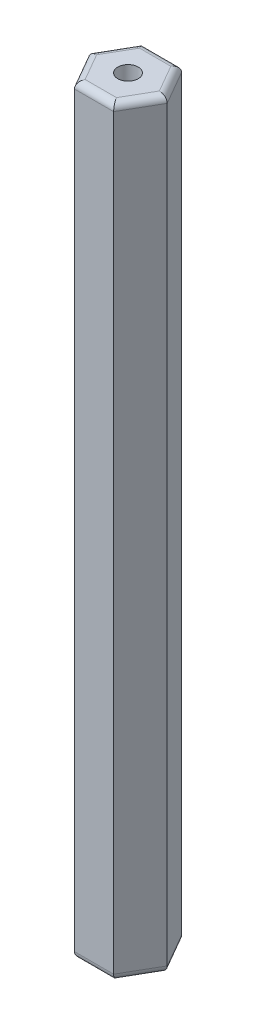
from build123d import *

# Parameters (mm, degrees)
RESSALTO_EXTRUS_O1_DEPTH = 56
FILETE1_R                = 0.5
ESBO_O2_R                = 0.751353762
CORTE_EXTRUS_O1_DEPTH    = 57


with BuildPart() as part:
    # Esboço1 → Ressalto-extrusão1 (new body)
    with BuildSketch(Plane.XZ.offset(30)):
        Polygon((-1.443375673, -2.5), (1.443375673, -2.5), (2.886751346, 0), (1.443375673, 2.5), (-1.443375673, 2.5), (-2.886751346, 0), align=None)
    extrude(amount=-RESSALTO_EXTRUS_O1_DEPTH)

    # Filete1
    filete1_edges = [part.edges().sort_by_distance(p)[0] for p in [
        (2.165063509, 26, -1.25),
        (2.165063509, 26, 1.25),
        (0, 26, 2.5),
        (-2.165063509, 26, 1.25),
        (-2.165063509, 26, -1.25),
        (-2.165063509, -30, 1.25),
        (0, -30, 2.5),
        (2.165063509, -30, 1.25),
        (2.165063509, -30, -1.25),
        (0, -30, -2.5),
        (-2.165063509, -30, -1.25),
        (0, 26, -2.5),
    ]]
    fillet(filete1_edges, radius=FILETE1_R)

    # Esboço2 → Corte-extrusão1 (cut, through all)
    with BuildSketch(Plane.XZ.offset(30)):
        Circle(ESBO_O2_R)
    extrude(amount=-CORTE_EXTRUS_O1_DEPTH, mode=Mode.SUBTRACT)


solid = part.part
